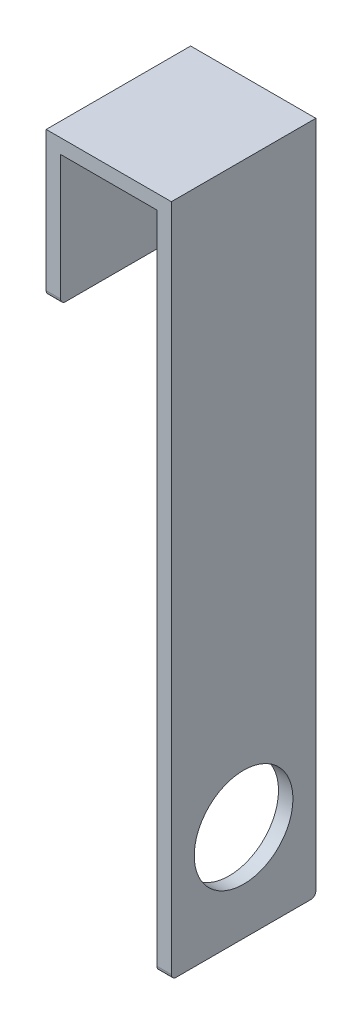
from build123d import *

# Parameters (mm, degrees)
EXTRUDE_1_DEPTH     = 30
SKETCH_2_R          = 10.25
CUT_EXTRUDE_1_DEPTH = 30
FILLET_2_R          = 1
FILLET_3_R          = 1
FILLET_4_R          = 1
FILLET_5_R          = 1


with BuildPart() as part:
    # Эскиз1 → Бобышка-Вытянуть1 (new body)
    with BuildSketch(Plane.XY):
        Polygon((-20, 7.029837238), (-20, 34.029837238), (0, 34.029837238), (0, -102.970162762), (3, -102.970162762), (3, 37.029837238), (-23, 37.029837238), (-23, 7.029837238), align=None)
    extrude(amount=EXTRUDE_1_DEPTH)

    # Эскиз2 → Вырез-Вытянуть1 (cut)
    with BuildSketch(Plane(origin=(3, 0, 0), x_dir=(0, 0, -1), z_dir=(1, 0, 0))):
        with Locations((-15, -82.970162762)):
            Circle(SKETCH_2_R)
    extrude(amount=-CUT_EXTRUDE_1_DEPTH, mode=Mode.SUBTRACT)

    # Скругление2
    fillet_2_edges = [part.edges().sort_by_distance(p)[0] for p in [
        (1.5, -102.970162762, 30),
    ]]
    fillet(fillet_2_edges, radius=FILLET_2_R)

    # Скругление3
    fillet_3_edges = [part.edges().sort_by_distance(p)[0] for p in [
        (1.5, -102.970162762, 0),
    ]]
    fillet(fillet_3_edges, radius=FILLET_3_R)

    # Скругление4
    fillet_4_edges = [part.edges().sort_by_distance(p)[0] for p in [
        (-21.5, 7.029837238, 30),
    ]]
    fillet(fillet_4_edges, radius=FILLET_4_R)

    # Скругление5
    fillet_5_edges = [part.edges().sort_by_distance(p)[0] for p in [
        (-21.5, 7.029837238, 0),
    ]]
    fillet(fillet_5_edges, radius=FILLET_5_R)


solid = part.part
